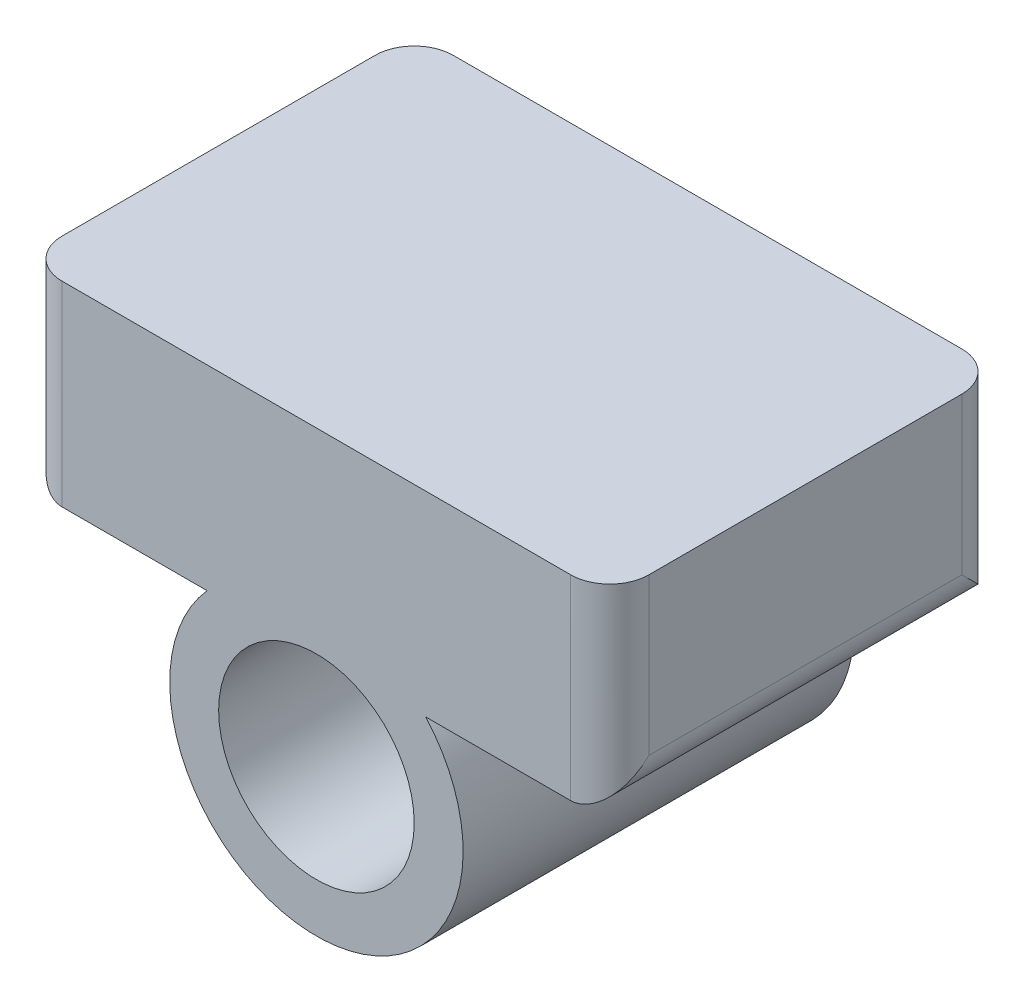
from build123d import *

# Parameters (mm, degrees)
SKETCH1_R           = 7.5
SKETCH1_R_2         = 5
SKETCH1_W           = 30
SKETCH1_H           = 10
BOSS_EXTRUDE1_DEPTH = 20
FILLET1_R           = 2


with BuildPart() as part:
    # Sketch1 → Boss-Extrude1 (new body)
    with BuildSketch(Plane.XY):
        Circle(SKETCH1_R)
        Circle(SKETCH1_R_2, mode=Mode.SUBTRACT)
        with Locations((0, 10)):
            Rectangle(SKETCH1_W, SKETCH1_H)
    extrude(amount=BOSS_EXTRUDE1_DEPTH)

    # Fillet1
    fillet1_edges = [part.edges().sort_by_distance(p)[0] for p in [
        (-15, 5, 10),
        (15, 5, 10),
        (15, 10, 20),
        (-15, 10, 20),
        (-15, 10, 0),
        (15, 10, 0),
    ]]
    fillet(fillet1_edges, radius=FILLET1_R)


solid = part.part
